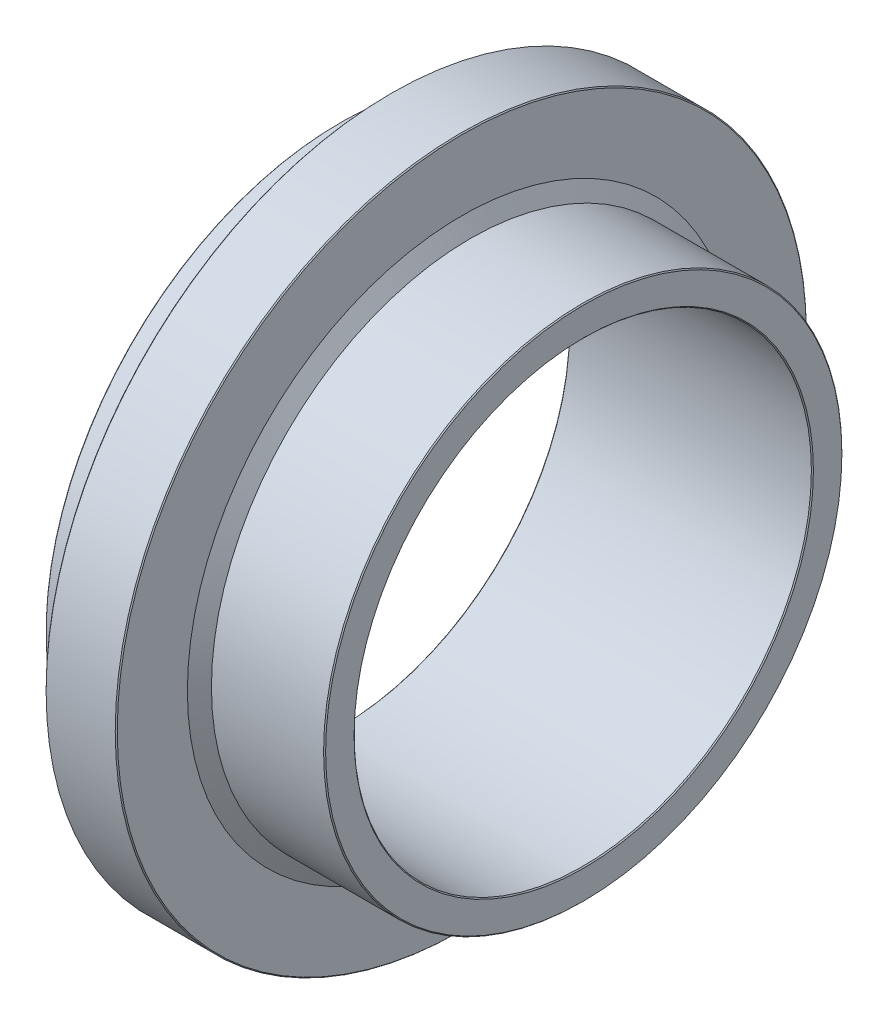
from build123d import *


with BuildPart() as part:
    # Esquisse1 → Révolution1 (revolve)
    with BuildSketch(Plane.XY, mode=Mode.PRIVATE) as r_volution1_sk:
        Polygon((0, 45.2), (0, 50.8), (-0.2, 51), (-22.267949192, 51), (-24, 54), (-24, 67.8), (-24.2, 68), (-37.8, 68), (-38, 67.8), (-38, 58), (-47.8, 58), (-48, 57.8), (-48, 45.2), (-47.8, 45), (-0.2, 45), align=None)
    revolve(r_volution1_sk.sketch.rotate(Axis((0, 0, 0), (-1, 0, 0)), 90), axis=Axis((0, 0, 0), (-1, 0, 0)))  # turned: the seam where the file's is


solid = part.part
